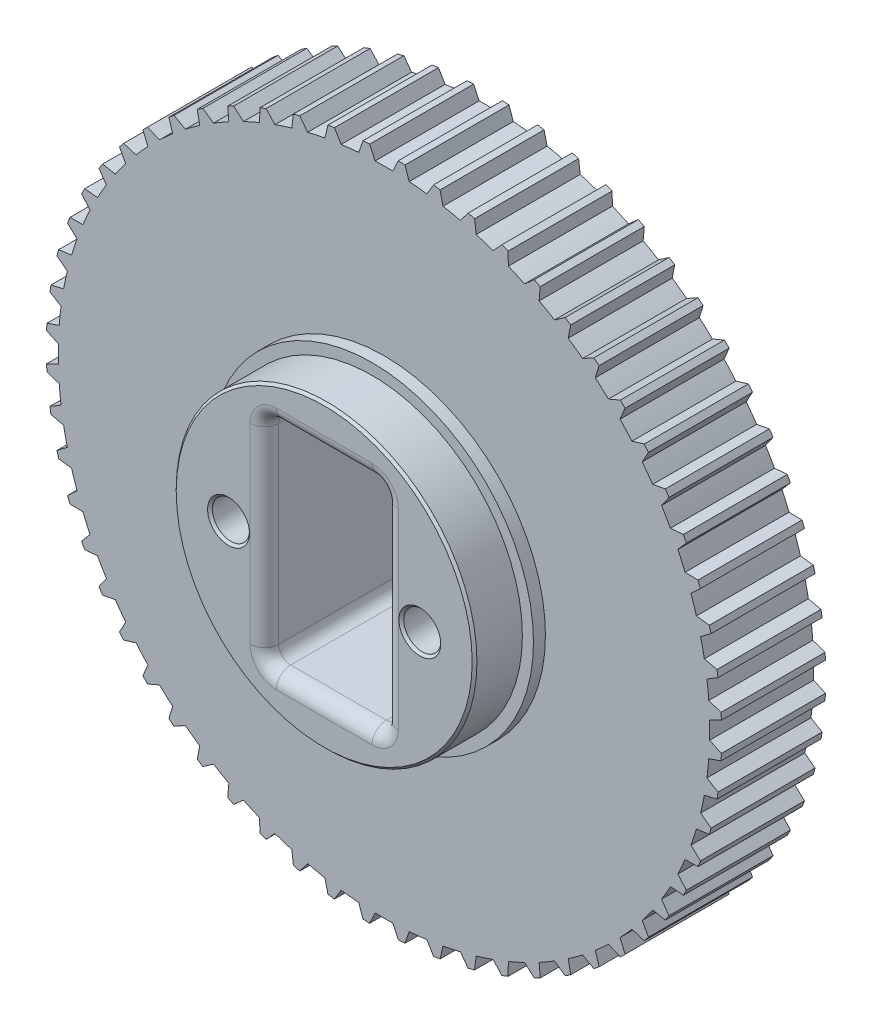
from build123d import *

# Parameters (mm, degrees)
SCHNITT_LINEAR_AUSTRAGEN1_DEPTH      = 42.017285381
KREISMUSTER1_COUNT                   = 60
SCHNITT_LINEAR_AUSTRAGEN2_DEPTH      = 41.982163193
SCHNITT_LINEAR_AUSTRAGEN2_DEPTH_BACK = 41.982163193
SKIZZE4_R                            = 1.55
VERRUNDUNG1_R                        = 1.2
FASE1_SIZE                           = 0.2
SKETCH2_R                            = 13.5
SKETCH2_R_2                          = 12.575
BOSS_EXTRUDE2_DEPTH                  = 1
BOSS_EXTRUDE3_START                  = 2
SKETCH3_R                            = 13.5
SKETCH3_R_2                          = 12.575
BOSS_EXTRUDE3_DEPTH                  = 2


with BuildPart() as part:
    # Skizze1 → Rotation1 (revolve)
    with BuildSketch(Plane(origin=(0, 0, 0), x_dir=(0, 0, -1), z_dir=(1, 0, 0))):
        Polygon((-4.35, 28.24), (4.35, 28.24), (4.35, 12.575), (9.35, 12.575), (9.35, 0), (-9.35, 0), (-9.35, 12.575), (-4.35, 12.575), align=None)
    revolve(axis=Axis((0, 0, 46.515199561), (0, 0, -1)))

    # Skizze2 → Schnitt-Linear austragen1 (cut, symmetric)
    with BuildSketch(Plane.XY):
        with BuildLine():
            Line((-1.2, 28.21449273), (-0.740887417, 27.229922619))
            ThreePointArc((-0.740887417, 27.229922619), (0, 27.24), (0.740887417, 27.229922619))
            Line((0.740887417, 27.229922619), (1.2, 28.21449273))
            ThreePointArc((1.2, 28.21449273), (0, 28.24), (-1.2, 28.21449273))
        make_face()
    schnitt_linear_austragen1 = extrude(amount=SCHNITT_LINEAR_AUSTRAGEN1_DEPTH, both=True, mode=Mode.SUBTRACT)

    # Kreismuster1: Schnitt-Linear austragen1 ×60 about axis
    kreismuster1_axis = Axis((0, 0, 51.659283785), (0, 0, -1))
    for i in range(1, KREISMUSTER1_COUNT):
        add(schnitt_linear_austragen1.rotate(kreismuster1_axis, i * 360 / KREISMUSTER1_COUNT), mode=Mode.SUBTRACT)

    # Skizze3 → Rotation2 (revolve)
    with BuildSketch(Plane(origin=(0, 0, 0), x_dir=(0, 0, -1), z_dir=(1, 0, 0))):
        with BuildLine():
            Line((4.35, 13), (4.35, 14.5))
            Line((4.35, 14.5), (3.85, 14.5))
            Line((3.85, 14.5), (3.85, 14.25))
            Line((3.85, 14.25), (3.196446609, 13.596446609))
            ThreePointArc((3.196446609, 13.596446609), (3.088060234, 13.434234935), (3.05, 13.242893219))
            Line((3.05, 13.242893219), (3.05, 13))
            Line((3.05, 13), (4.35, 13))
        make_face()
    revolve(axis=Axis((0, 0, -11.03129214), (0, 0, 1)))

    # Skizze4 → Schnitt-Linear austragen2 (cut, two sides: drawn at the far end of the back side and taken through both)
    with BuildSketch(Plane.XY.offset(-SCHNITT_LINEAR_AUSTRAGEN2_DEPTH_BACK)):
        with Locations((-8, 0)):
            Circle(SKIZZE4_R)
        with Locations((8, 0)):
            Circle(SKIZZE4_R)
        with BuildLine():
            Line((4, 9), (-4, 9))
            ThreePointArc((-4, 9), (-4.707106781, 8.707106781), (-5, 8))
            Line((-5, 8), (-5, -8))
            ThreePointArc((-5, -8), (-4.707106781, -8.707106781), (-4, -9))
            Line((-4, -9), (4, -9))
            ThreePointArc((4, -9), (4.707106781, -8.707106781), (5, -8))
            Line((5, -8), (5, 8))
            ThreePointArc((5, 8), (4.707106781, 8.707106781), (4, 9))
        make_face()
    extrude(amount=SCHNITT_LINEAR_AUSTRAGEN2_DEPTH + SCHNITT_LINEAR_AUSTRAGEN2_DEPTH_BACK, mode=Mode.SUBTRACT)

    # Verrundung1
    verrundung1_edges = [part.edges().sort_by_distance(p)[0] for p in [
        (-4.707106781, 8.707106781, -9.35),
        (0, 9, -9.35),
        (4.707106781, 8.707106781, -9.35),
        (5, 0, -9.35),
        (4.707106781, -8.707106781, -9.35),
        (0, -9, -9.35),
        (-4.707106781, -8.707106781, -9.35),
        (-4.707106781, 8.707106781, 9.35),
        (0, 9, 9.35),
        (4.707106781, 8.707106781, 9.35),
        (5, 0, 9.35),
        (4.707106781, -8.707106781, 9.35),
        (0, -9, 9.35),
        (-4.707106781, -8.707106781, 9.35),
        (-5, 0, -9.35),
        (-5, 0, 9.35),
    ]]
    fillet(verrundung1_edges, radius=VERRUNDUNG1_R)

    # Fase1
    fase1_edges = [part.edges().sort_by_distance(p)[0] for p in [
        (-9.55, 0, -9.35),
        (6.45, 0, -9.35),
        (6.45, 0, 9.35),
        (-9.55, 0, 9.35),
        (0, -12.575, -9.35),
        (0, -12.575, 9.35),
    ]]
    chamfer(fase1_edges, length=FASE1_SIZE)

    # Sketch2 → Boss-Extrude2 (add)
    with BuildSketch(Plane.XY.offset(4.35)):
        Circle(SKETCH2_R)
        Circle(SKETCH2_R_2, mode=Mode.SUBTRACT)
    extrude(amount=BOSS_EXTRUDE2_DEPTH)

    # Sketch3 → Boss-Extrude3 (add)
    with BuildSketch(Plane(origin=(0, 0, -4.35), x_dir=(-1, 0, 0), z_dir=(0, 0, -1)).offset(BOSS_EXTRUDE3_START)):
        Circle(SKETCH3_R)
        Circle(SKETCH3_R_2, mode=Mode.SUBTRACT)
    extrude(amount=-BOSS_EXTRUDE3_DEPTH)


solid = part.part
